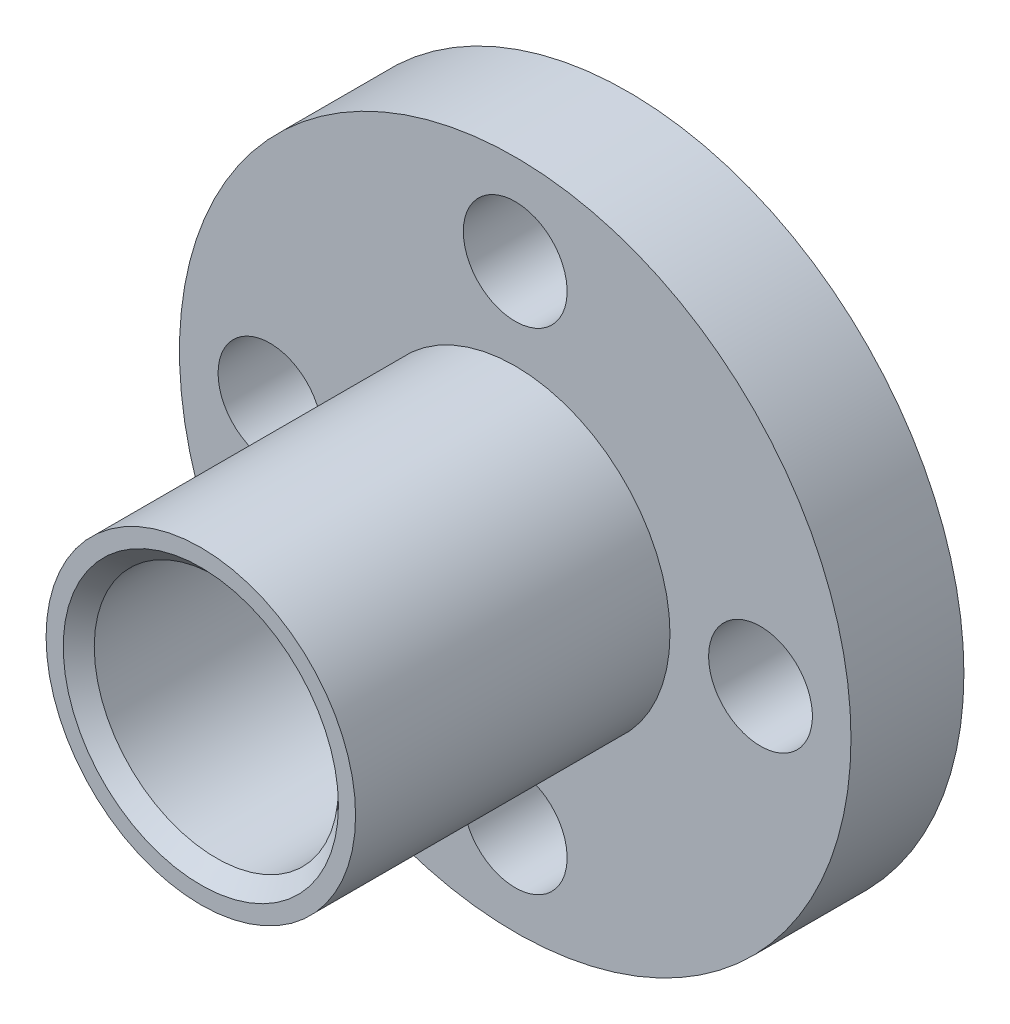
from build123d import *

# Parameters (mm, degrees)
SKETCH1_R           = 5.07
SKETCH1_R_2         = 4
BOSS_EXTRUDE1_DEPTH = 10.3
SKETCH1_3_R         = 11
SKETCH1_3_R_2       = 5.07
SKETCH1_3_R_3       = 4
BOSS_EXTRUDE2_DEPTH = 3.7
SKETCH2_R           = 5.07
SKETCH2_R_2         = 4
BOSS_EXTRUDE3_DEPTH = 1.5
CHAMFER1_SIZE       = 0.508
SKETCH3_R           = 1.7
CUT_EXTRUDE1_DEPTH  = 4.294


with BuildPart() as part:
    # Sketch1 → Boss-Extrude1 (new body)
    with BuildSketch(Plane.XY):
        with Locations(Location((0, 0, 0), (0, 0, 180))):
            Circle(SKETCH1_R)
        with Locations(Location((0, 0, 0), (0, 0, 180))):
            Circle(SKETCH1_R_2, mode=Mode.SUBTRACT)
    extrude(amount=BOSS_EXTRUDE1_DEPTH)

    # Sketch1_3 → Boss-Extrude2 (add)
    with BuildSketch(Plane.XY):
        Circle(SKETCH1_3_R)
        with Locations(Location((0, 0, 0), (0, 0, 180))):
            Circle(SKETCH1_3_R_2, mode=Mode.SUBTRACT)
        with Locations(Location((0, 0, 0), (0, 0, 180))):
            Circle(SKETCH1_3_R_2)
        with Locations(Location((0, 0, 0), (0, 0, 180))):
            Circle(SKETCH1_3_R_3, mode=Mode.SUBTRACT)
    extrude(amount=-BOSS_EXTRUDE2_DEPTH)

    # Sketch2 → Boss-Extrude3 (add)
    with BuildSketch(Plane(origin=(0, 0, -3.7), x_dir=(-1, 0, 0), z_dir=(0, 0, -1))):
        Circle(SKETCH2_R)
        Circle(SKETCH2_R_2, mode=Mode.SUBTRACT)
    extrude(amount=BOSS_EXTRUDE3_DEPTH)

    # Chamfer1
    chamfer1_edges = [part.edges().sort_by_distance(p)[0] for p in [
        (4, 0, -5.2),
        (4, 0, 10.3),
    ]]
    chamfer(chamfer1_edges, length=CHAMFER1_SIZE)

    # Sketch3 → Cut-Extrude1 (cut)
    with BuildSketch(Plane(origin=(0, 0, -3.7), x_dir=(-1, 0, 0), z_dir=(0, 0, -1))):
        with Locations((-8.035, 0)):
            Circle(SKETCH3_R)
        with Locations((0, 8.035)):
            Circle(SKETCH3_R)
        with Locations((8.035, 0)):
            Circle(SKETCH3_R)
        with Locations((0, -8.035)):
            Circle(SKETCH3_R)
    extrude(amount=-CUT_EXTRUDE1_DEPTH, mode=Mode.SUBTRACT)


solid = part.part
